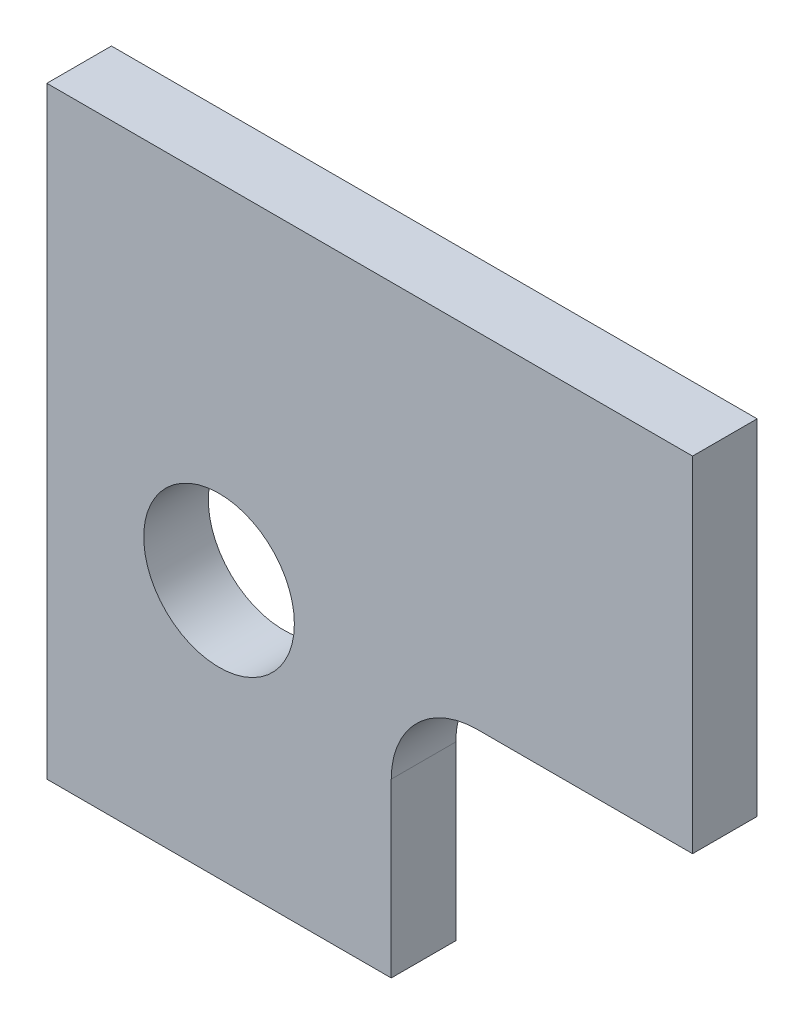
from build123d import *

# Parameters (mm, degrees)
SKETCH1_R           = 1.75
BOSS_EXTRUDE1_DEPTH = 1.5


with BuildPart() as part:
    # Sketch1 → Boss-Extrude1 (new body)
    with BuildSketch(Plane.XY):
        with BuildLine():
            Line((4, -6), (-4, -6))
            Line((-4, -6), (-4, 8))
            Line((-4, 8), (11, 8))
            Line((11, 8), (11, 0))
            Line((11, 0), (6, 0))
            ThreePointArc((6, 0), (4.585786438, -0.585786438), (4, -2))
            Line((4, -2), (4, -6))
        make_face()
        Circle(SKETCH1_R, mode=Mode.SUBTRACT)
    extrude(amount=BOSS_EXTRUDE1_DEPTH)


solid = part.part
